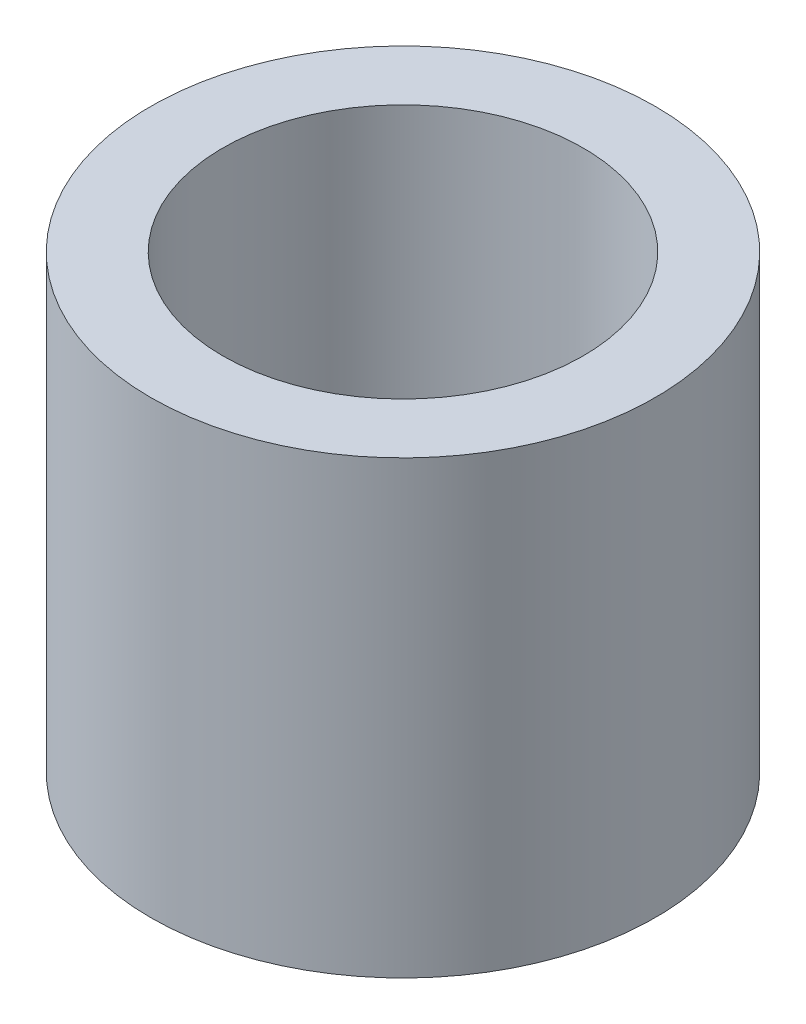
from build123d import *

# Parameters (mm, degrees)
SKETCH1_R           = 1.4
SKETCH1_R_2         = 1
BOSS_EXTRUDE1_DEPTH = 2.5


with BuildPart() as part:
    # Sketch1 → Boss-Extrude1 (new body)
    with BuildSketch(Plane(origin=(0, 0, 0), x_dir=(1, 0, 0), z_dir=(0, 1, 0))):
        Circle(SKETCH1_R)
        Circle(SKETCH1_R_2, mode=Mode.SUBTRACT)
    extrude(amount=BOSS_EXTRUDE1_DEPTH)


solid = part.part
